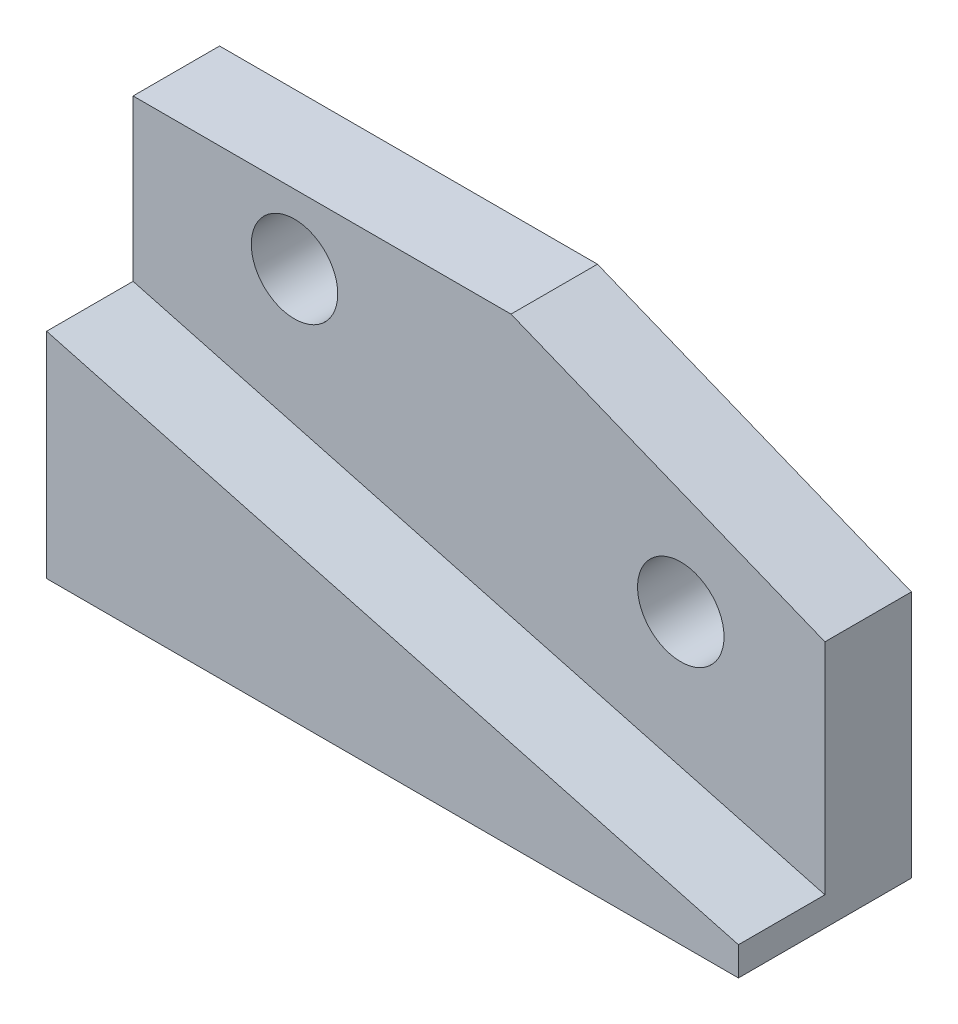
from build123d import *

# Parameters (mm, degrees)
BOSS_EXTRUDE1_DEPTH = 15
SKETCH1_7_R         = 7.5
BOSS_EXTRUDE5_DEPTH = 15


with BuildPart() as part:
    # Sketch1 → Boss-Extrude1 (new body)
    with BuildSketch(Plane.XY):
        Polygon((60, -32.5), (60, -27.5), (-60, 4.653903092), (-60, -32.5), align=None)
    extrude(amount=BOSS_EXTRUDE1_DEPTH)

    # Sketch1_7 → Boss-Extrude5 (add)
    with BuildSketch(Plane.XY):
        Polygon((60, -32.5), (60, 10.5), (5.548089225, 32.5), (-60, 32.5), (-60, -32.5), align=None)
        with Locations((35, 2.5)):
            Circle(SKETCH1_7_R, mode=Mode.SUBTRACT)
        with Locations((-32, 20.5)):
            Circle(SKETCH1_7_R, mode=Mode.SUBTRACT)
    extrude(amount=-BOSS_EXTRUDE5_DEPTH)


solid = part.part
